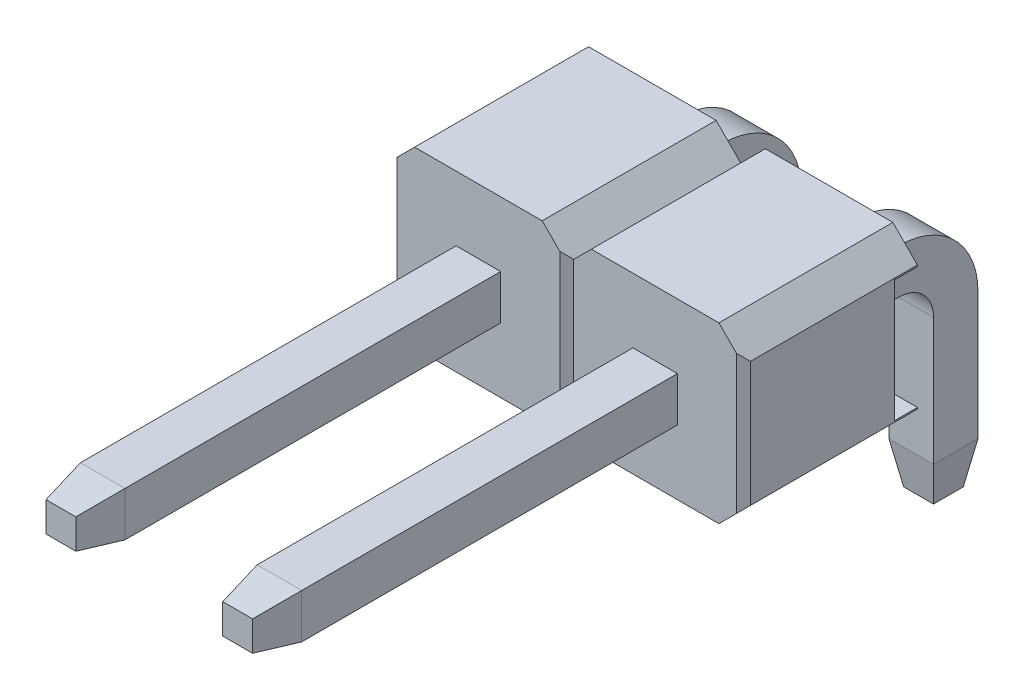
from build123d import *
from OCP.BRepFilletAPI import BRepFilletAPI_MakeChamfer

# Parameters (mm, degrees)
EXTRUDE1_DEPTH          = 1.25
CUT_EXTRUDE3_DEPTH      = 3.176671771
LPATTERN4_COUNT         = 2
LPATTERN4_PITCH         = 2.54
CUT_EXTRUDE1_DEPTH      = 5.20013095
CUT_EXTRUDE1_DEPTH_BACK = 5.20013095
SKETCH2_W               = 1.752893218
SKETCH2_H               = 0.33
EXTRUDE_THIN1_DEPTH     = 0.32
LPATTERN5_COUNT         = 2
LPATTERN5_PITCH         = 2.54
CHAMFER2_SIZE           = 0.6
CHAMFER2_SIZE2          = 0.105796188
FILLET1_R               = 0.5
FILLET2_R               = 1.14


with BuildPart() as part:
    # Sketch1 → Extrude1 (new, symmetric)
    with BuildSketch(Plane.XY):
        Polygon((-1.27, 0.896446609), (-0.916446609, 1.25), (0.916446609, 1.25), (1.27, 0.896446609), (1.27, -0.896446609), (0.916446609, -1.25), (-0.916446609, -1.25), (-1.27, -0.896446609), align=None)
    extrude1 = extrude(amount=EXTRUDE1_DEPTH, both=True)

    # Sketch4 → Cut-Extrude3 (cut, symmetric)
    with BuildSketch(Plane(origin=(0, 0, 0), x_dir=(1, 0, 0), z_dir=(0, 1, 0))):
        Polygon((-1.27, -1.15), (-1.17, -1.25), (-1.27, -1.25), align=None)
        Polygon((1.17, -1.25), (1.27, -1.15), (1.27, -1.25), align=None)
    cut_extrude3 = extrude(amount=CUT_EXTRUDE3_DEPTH, both=True, mode=Mode.SUBTRACT)

    # LPattern4: Extrude1, Cut-Extrude3 ×2
    with Locations(*[(-i * LPATTERN4_PITCH, 0, 0) for i in range(1, LPATTERN4_COUNT)]):
        add(extrude1)
        add(cut_extrude3, mode=Mode.SUBTRACT)

    # Sketch2 → Cut-Extrude1 (cut, two sides: drawn at the far end of the back side and taken through both)
    with BuildSketch(Plane(origin=(0, 0, 0), x_dir=(0, -1, 0), z_dir=(1, 0, 0)).offset(-CUT_EXTRUDE1_DEPTH_BACK)):
        with Locations((0, 1.085)):
            Rectangle(SKETCH2_W, SKETCH2_H)
    extrude(amount=CUT_EXTRUDE1_DEPTH + CUT_EXTRUDE1_DEPTH_BACK, mode=Mode.SUBTRACT)

    # Sketch3 → Extrude-Thin1 (add, symmetric)
    with BuildSketch(Plane(origin=(0, 0, 0), x_dir=(0, 0, -1), z_dir=(1, 0, 0))):
        Polygon((-7.25, -0.32), (2.43, -0.32), (2.43, -3.25), (3.07, -3.25), (3.07, 0.32), (-7.25, 0.32), align=None)
    extrude_thin1 = extrude(amount=EXTRUDE_THIN1_DEPTH, both=True)

    # LPattern5: Extrude-Thin1 ×2
    with Locations(*[(-i * LPATTERN5_PITCH, 0, 0) for i in range(1, LPATTERN5_COUNT)]):
        add(extrude_thin1)

    # Chamfer2: one chamfer whose edges measure the first distance from different faces: ONE call of the kernel's chamfer builder (chamfer() names one face for all edges)
    chamfer2_edges_1 = [part.edges().sort_by_distance(p)[0] for p in [
        (0.32, 0, 7.25),
    ]]
    chamfer2_side_1 = [part.faces().sort_by_distance(p)[0] for p in [
        (0.32, 0, 4.25),
    ]]
    chamfer2_edges_2 = [part.edges().sort_by_distance(p)[0] for p in [
        (0, -0.32, 7.25),
    ]]
    chamfer2_side_2 = [part.faces().sort_by_distance(p)[0] for p in [
        (0, -0.32, 4.25),
    ]]
    chamfer2_edges_3 = [part.edges().sort_by_distance(p)[0] for p in [
        (-0.32, 0, 7.25),
    ]]
    chamfer2_side_3 = [part.faces().sort_by_distance(p)[0] for p in [
        (-0.32, 0, 4.25),
    ]]
    chamfer2_edges_4 = [part.edges().sort_by_distance(p)[0] for p in [
        (0, 0.32, 7.25),
    ]]
    chamfer2_side_4 = [part.faces().sort_by_distance(p)[0] for p in [
        (0, 0.32, 4.25),
    ]]
    chamfer2_edges_5 = [part.edges().sort_by_distance(p)[0] for p in [
        (0.32, -3.25, -2.75),
    ]]
    chamfer2_side_5 = [part.faces().sort_by_distance(p)[0] for p in [
        (0.32, -1.029537402, -2.430462598),
    ]]
    chamfer2_edges_6 = [part.edges().sort_by_distance(p)[0] for p in [
        (0, -3.25, -3.07),
    ]]
    chamfer2_side_6 = [part.faces().sort_by_distance(p)[0] for p in [
        (0, -1.465, -3.07),
    ]]
    chamfer2_edges_7 = [part.edges().sort_by_distance(p)[0] for p in [
        (-0.32, -3.25, -2.75),
    ]]
    chamfer2_side_7 = [part.faces().sort_by_distance(p)[0] for p in [
        (-0.32, -1.029537402, -2.430462598),
    ]]
    chamfer2_edges_8 = [part.edges().sort_by_distance(p)[0] for p in [
        (0, -3.25, -2.43),
    ]]
    chamfer2_side_8 = [part.faces().sort_by_distance(p)[0] for p in [
        (0, -1.785, -2.43),
    ]]
    chamfer2_edges_9 = [part.edges().sort_by_distance(p)[0] for p in [
        (-2.22, -3.25, -2.75),
    ]]
    chamfer2_side_9 = [part.faces().sort_by_distance(p)[0] for p in [
        (-2.22, -1.029537402, -2.430462598),
    ]]
    chamfer2_edges_10 = [part.edges().sort_by_distance(p)[0] for p in [
        (-2.54, -3.25, -3.07),
    ]]
    chamfer2_side_10 = [part.faces().sort_by_distance(p)[0] for p in [
        (-2.54, -1.465, -3.07),
    ]]
    chamfer2_edges_11 = [part.edges().sort_by_distance(p)[0] for p in [
        (-2.86, -3.25, -2.75),
    ]]
    chamfer2_side_11 = [part.faces().sort_by_distance(p)[0] for p in [
        (-2.86, -1.029537402, -2.430462598),
    ]]
    chamfer2_edges_12 = [part.edges().sort_by_distance(p)[0] for p in [
        (-2.54, -3.25, -2.43),
    ]]
    chamfer2_side_12 = [part.faces().sort_by_distance(p)[0] for p in [
        (-2.54, -1.785, -2.43),
    ]]
    chamfer2_edges_13 = [part.edges().sort_by_distance(p)[0] for p in [
        (-2.22, 0, 7.25),
    ]]
    chamfer2_side_13 = [part.faces().sort_by_distance(p)[0] for p in [
        (-2.22, 0, 4.25),
    ]]
    chamfer2_edges_14 = [part.edges().sort_by_distance(p)[0] for p in [
        (-2.54, -0.32, 7.25),
    ]]
    chamfer2_side_14 = [part.faces().sort_by_distance(p)[0] for p in [
        (-2.54, -0.32, 4.25),
    ]]
    chamfer2_edges_15 = [part.edges().sort_by_distance(p)[0] for p in [
        (-2.86, 0, 7.25),
    ]]
    chamfer2_side_15 = [part.faces().sort_by_distance(p)[0] for p in [
        (-2.86, 0, 4.25),
    ]]
    chamfer2_edges_16 = [part.edges().sort_by_distance(p)[0] for p in [
        (-2.54, 0.32, 7.25),
    ]]
    chamfer2_side_16 = [part.faces().sort_by_distance(p)[0] for p in [
        (-2.54, 0.32, 4.25),
    ]]
    chamfer2 = BRepFilletAPI_MakeChamfer(part.part.solid().wrapped)
    for e in chamfer2_edges_1:
        chamfer2.Add(CHAMFER2_SIZE, CHAMFER2_SIZE2, e.wrapped, chamfer2_side_1[0].wrapped)  # the first distance lies on this face
    for e in chamfer2_edges_2:
        chamfer2.Add(CHAMFER2_SIZE, CHAMFER2_SIZE2, e.wrapped, chamfer2_side_2[0].wrapped)  # the first distance lies on this face
    for e in chamfer2_edges_3:
        chamfer2.Add(CHAMFER2_SIZE, CHAMFER2_SIZE2, e.wrapped, chamfer2_side_3[0].wrapped)  # the first distance lies on this face
    for e in chamfer2_edges_4:
        chamfer2.Add(CHAMFER2_SIZE, CHAMFER2_SIZE2, e.wrapped, chamfer2_side_4[0].wrapped)  # the first distance lies on this face
    for e in chamfer2_edges_5:
        chamfer2.Add(CHAMFER2_SIZE, CHAMFER2_SIZE2, e.wrapped, chamfer2_side_5[0].wrapped)  # the first distance lies on this face
    for e in chamfer2_edges_6:
        chamfer2.Add(CHAMFER2_SIZE, CHAMFER2_SIZE2, e.wrapped, chamfer2_side_6[0].wrapped)  # the first distance lies on this face
    for e in chamfer2_edges_7:
        chamfer2.Add(CHAMFER2_SIZE, CHAMFER2_SIZE2, e.wrapped, chamfer2_side_7[0].wrapped)  # the first distance lies on this face
    for e in chamfer2_edges_8:
        chamfer2.Add(CHAMFER2_SIZE, CHAMFER2_SIZE2, e.wrapped, chamfer2_side_8[0].wrapped)  # the first distance lies on this face
    for e in chamfer2_edges_9:
        chamfer2.Add(CHAMFER2_SIZE, CHAMFER2_SIZE2, e.wrapped, chamfer2_side_9[0].wrapped)  # the first distance lies on this face
    for e in chamfer2_edges_10:
        chamfer2.Add(CHAMFER2_SIZE, CHAMFER2_SIZE2, e.wrapped, chamfer2_side_10[0].wrapped)  # the first distance lies on this face
    for e in chamfer2_edges_11:
        chamfer2.Add(CHAMFER2_SIZE, CHAMFER2_SIZE2, e.wrapped, chamfer2_side_11[0].wrapped)  # the first distance lies on this face
    for e in chamfer2_edges_12:
        chamfer2.Add(CHAMFER2_SIZE, CHAMFER2_SIZE2, e.wrapped, chamfer2_side_12[0].wrapped)  # the first distance lies on this face
    for e in chamfer2_edges_13:
        chamfer2.Add(CHAMFER2_SIZE, CHAMFER2_SIZE2, e.wrapped, chamfer2_side_13[0].wrapped)  # the first distance lies on this face
    for e in chamfer2_edges_14:
        chamfer2.Add(CHAMFER2_SIZE, CHAMFER2_SIZE2, e.wrapped, chamfer2_side_14[0].wrapped)  # the first distance lies on this face
    for e in chamfer2_edges_15:
        chamfer2.Add(CHAMFER2_SIZE, CHAMFER2_SIZE2, e.wrapped, chamfer2_side_15[0].wrapped)  # the first distance lies on this face
    for e in chamfer2_edges_16:
        chamfer2.Add(CHAMFER2_SIZE, CHAMFER2_SIZE2, e.wrapped, chamfer2_side_16[0].wrapped)  # the first distance lies on this face
    add(Compound.cast(chamfer2.Shape()), mode=Mode.REPLACE)

    # Fillet1
    fillet1_edges = [part.edges().sort_by_distance(p)[0] for p in [
        (0, -0.32, -2.43),
        (-2.54, -0.32, -2.43),
    ]]
    fillet(fillet1_edges, radius=FILLET1_R)

    # Fillet2
    fillet2_edges = [part.edges().sort_by_distance(p)[0] for p in [
        (0, 0.32, -3.07),
        (-2.54, 0.32, -3.07),
    ]]
    fillet(fillet2_edges, radius=FILLET2_R)


solid = part.part
